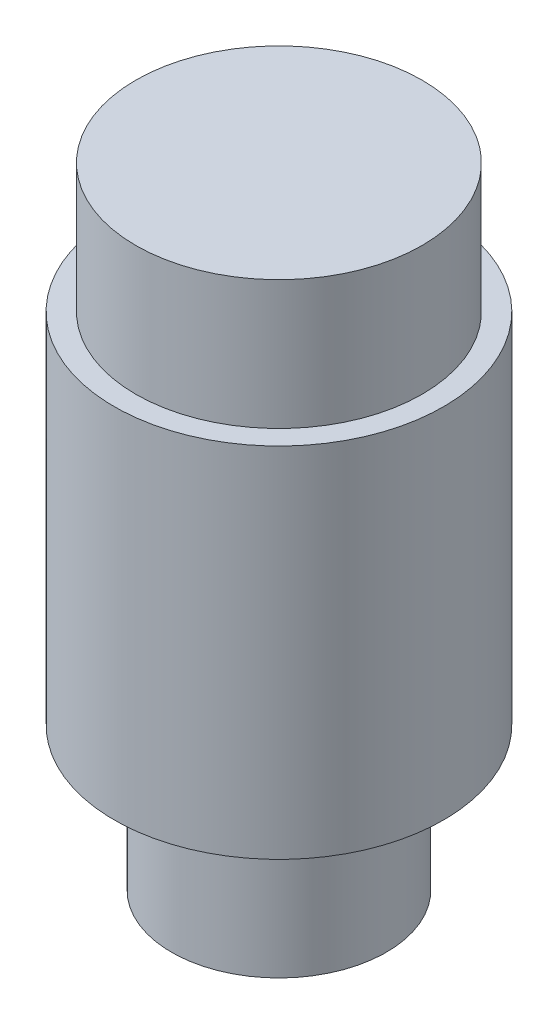
from build123d import *


with BuildPart() as part:
    # 草图1 → 旋转1 (revolve)
    with BuildSketch(Plane.XY):
        Polygon((0, 0), (10, 0), (10, -9), (11.5, -9), (11.5, -34), (7.5, -34), (7.5, -44), (0, -44), align=None)
    revolve(axis=Axis((0, -44, 0), (0, 1, 0)))


solid = part.part
